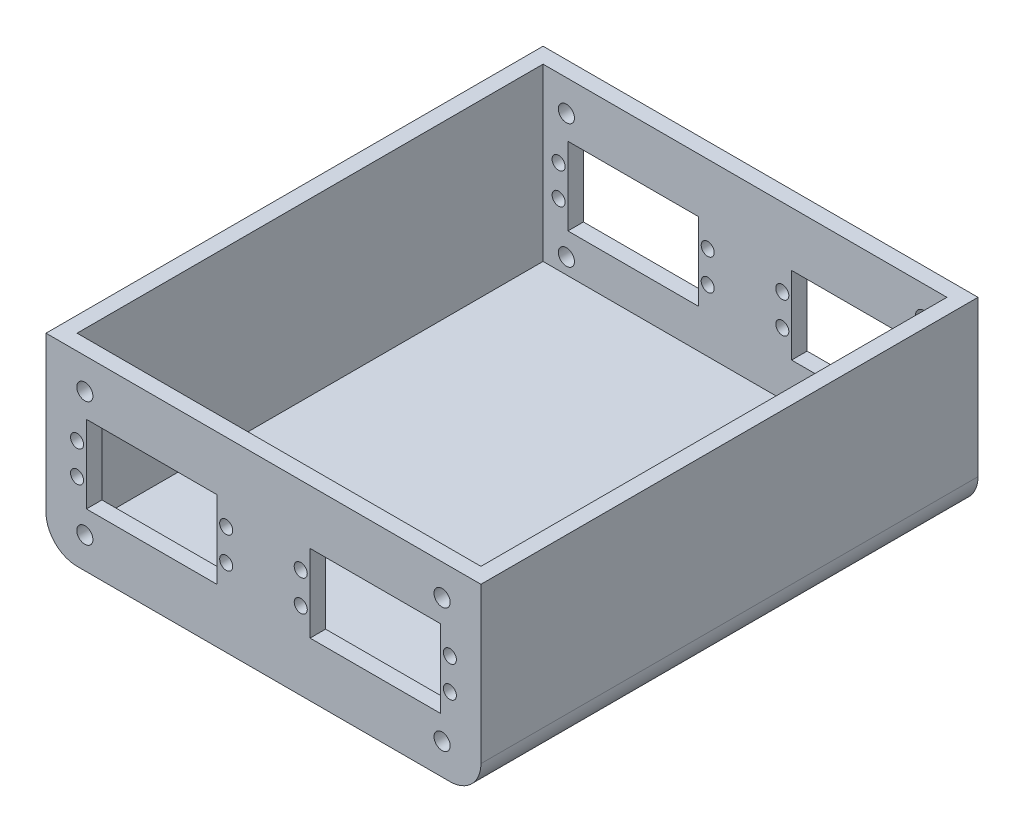
from build123d import *

# Parameters (mm, degrees)
SKETCH1_W           = 140
SKETCH1_H           = 60
BOSS_EXTRUDE1_DEPTH = 160
SHELL1_T            = -5
SKETCH2_R           = 2.6
SKETCH2_R_2         = 2.1
SKETCH2_W           = 42
SKETCH2_H           = 25
CUT_EXTRUDE1_DEPTH  = 161
FILLET1_R           = 10


with BuildPart() as part:
    # Sketch1 → Boss-Extrude1 (new body)
    with BuildSketch(Plane.XY):
        with Locations((-70, 30)):
            Rectangle(SKETCH1_W, SKETCH1_H)
    extrude(amount=BOSS_EXTRUDE1_DEPTH)

    # Shell1
    shell1_openings = [part.faces().sort_by_distance(p)[0] for p in [
        (-70, 60, 80),
    ]]
    offset(amount=SHELL1_T, openings=shell1_openings, kind=Kind.INTERSECTION)

    # Sketch2 → Cut-Extrude1 (cut, through all)
    with BuildSketch(Plane.XY.offset(160)):
        with Locations((-127.5, 50)):
            Circle(SKETCH2_R)
        with Locations((-127.5, 10)):
            Circle(SKETCH2_R)
        with Locations((-12.5, 10)):
            Circle(SKETCH2_R)
        with Locations((-12.5, 50)):
            Circle(SKETCH2_R)
        with Locations((-130, 35)):
            Circle(SKETCH2_R_2)
        with Locations((-130, 25)):
            Circle(SKETCH2_R_2)
        with Locations((-82, 25)):
            Circle(SKETCH2_R_2)
        with Locations((-82, 35)):
            Circle(SKETCH2_R_2)
        with Locations((-58, 25)):
            Circle(SKETCH2_R_2)
        with Locations((-58, 35)):
            Circle(SKETCH2_R_2)
        with Locations((-10, 25)):
            Circle(SKETCH2_R_2)
        with Locations((-10, 35)):
            Circle(SKETCH2_R_2)
        with Locations((-106, 30)):
            Rectangle(SKETCH2_W, SKETCH2_H)
        with Locations((-34, 30)):
            Rectangle(SKETCH2_W, SKETCH2_H)
    extrude(amount=-CUT_EXTRUDE1_DEPTH, mode=Mode.SUBTRACT)

    # Fillet1
    fillet1_edges = [part.edges().sort_by_distance(p)[0] for p in [
        (0, 0, 80),
        (-140, 0, 80),
    ]]
    fillet(fillet1_edges, radius=FILLET1_R)


solid = part.part
